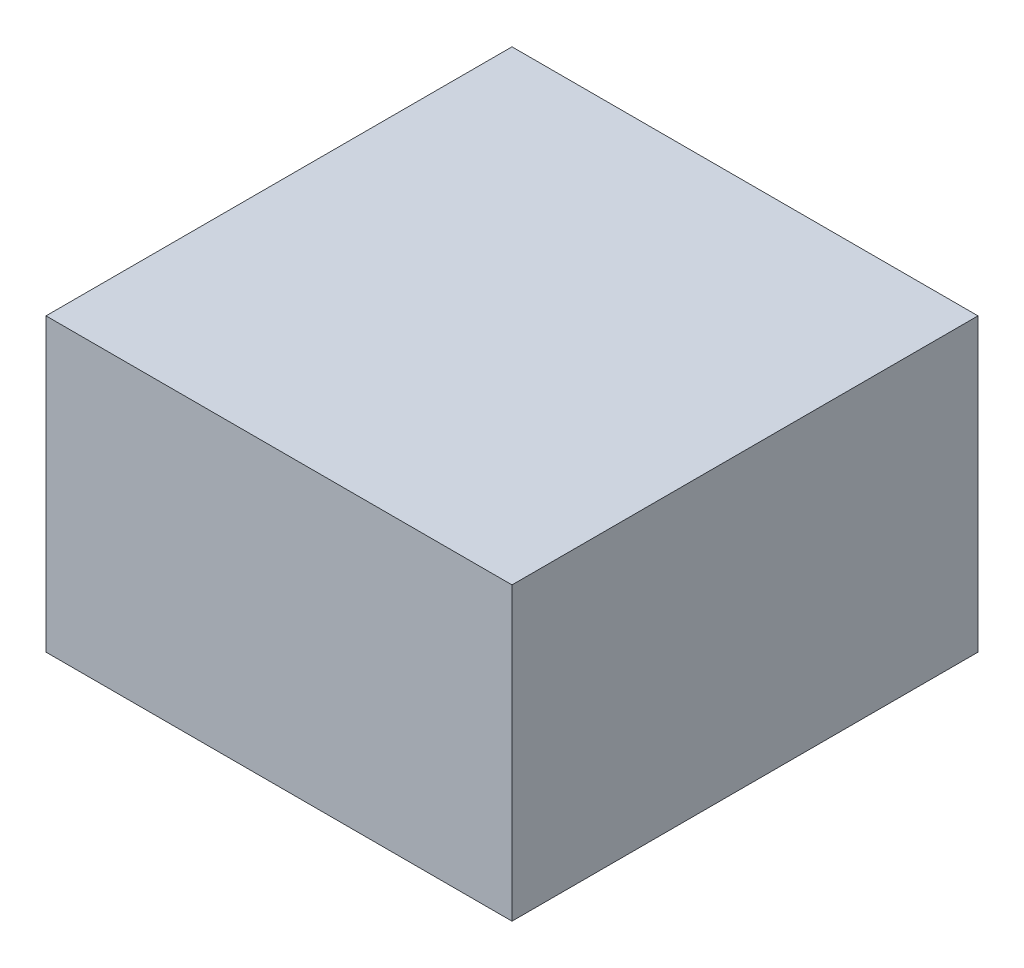
from build123d import *

# Parameters (mm, degrees)
SKETCH1_W           = 203.2
SKETCH1_H           = 203.2
BOSS_EXTRUDE1_DEPTH = 127


with BuildPart() as part:
    # Sketch1 → Boss-Extrude1 (new body)
    with BuildSketch(Plane(origin=(0, 0, 0), x_dir=(1, 0, 0), z_dir=(0, 1, 0))):
        Rectangle(SKETCH1_W, SKETCH1_H)
    extrude(amount=BOSS_EXTRUDE1_DEPTH)


solid = part.part
